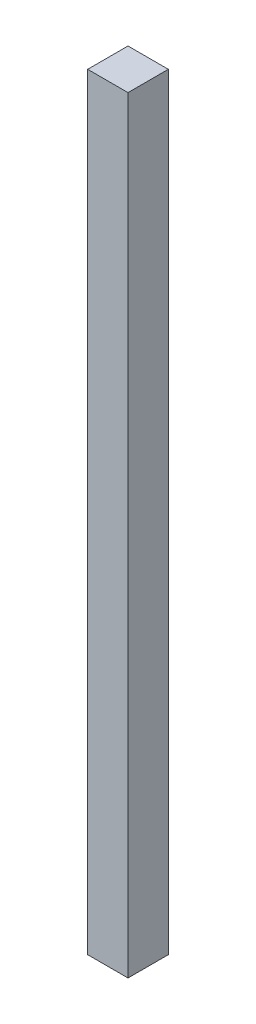
from build123d import *

# Parameters (mm, degrees)
SKETCH1_W           = 25.4
SKETCH1_H           = 25.4
BOSS_EXTRUDE1_DEPTH = 482.854


with BuildPart() as part:
    # Sketch1 → Boss-Extrude1 (new body)
    with BuildSketch(Plane(origin=(0, 0, 0), x_dir=(1, 0, 0), z_dir=(0, 1, 0))):
        with Locations((12.7, 12.7)):
            Rectangle(SKETCH1_W, SKETCH1_H)
    extrude(amount=BOSS_EXTRUDE1_DEPTH)


solid = part.part
